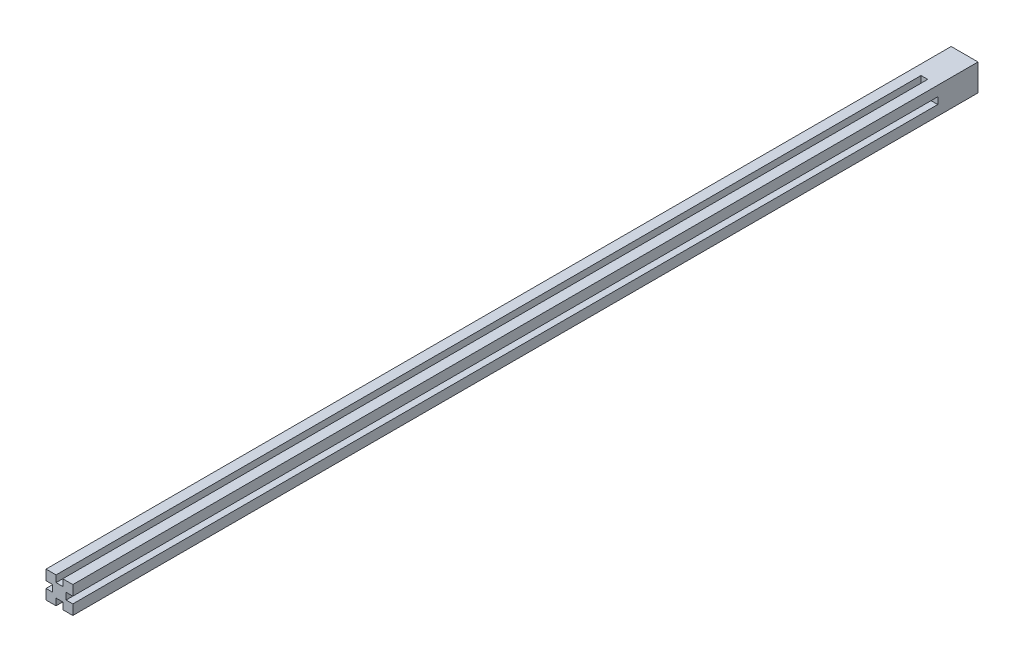
from build123d import *

# Parameters (mm, degrees)
SKETCH1_W           = 20
SKETCH1_H           = 20
BOSS_EXTRUDE1_DEPTH = 675
SKETCH1_3_W         = 5
SKETCH1_3_H         = 10
CUT_EXTRUDE1_DEPTH  = 645
CIRPATTERN1_COUNT   = 4


with BuildPart() as part:
    # Sketch1 → Boss-Extrude1 (new body)
    with BuildSketch(Plane.XY):
        Rectangle(SKETCH1_W, SKETCH1_H)
    extrude(amount=-BOSS_EXTRUDE1_DEPTH)

    # Sketch1_3 → Cut-Extrude1 (cut)
    with BuildSketch(Plane.XY):
        with Locations((0, 10)):
            Rectangle(SKETCH1_3_W, SKETCH1_3_H)
    cut_extrude1 = extrude(amount=-CUT_EXTRUDE1_DEPTH, mode=Mode.SUBTRACT)

    # CirPattern1: Cut-Extrude1 ×4 about axis
    cirpattern1_axis = Axis((0, 0, 32.25), (0, 0, -1))
    for i in range(1, CIRPATTERN1_COUNT):
        add(cut_extrude1.rotate(cirpattern1_axis, i * 360 / CIRPATTERN1_COUNT), mode=Mode.SUBTRACT)


solid = part.part
